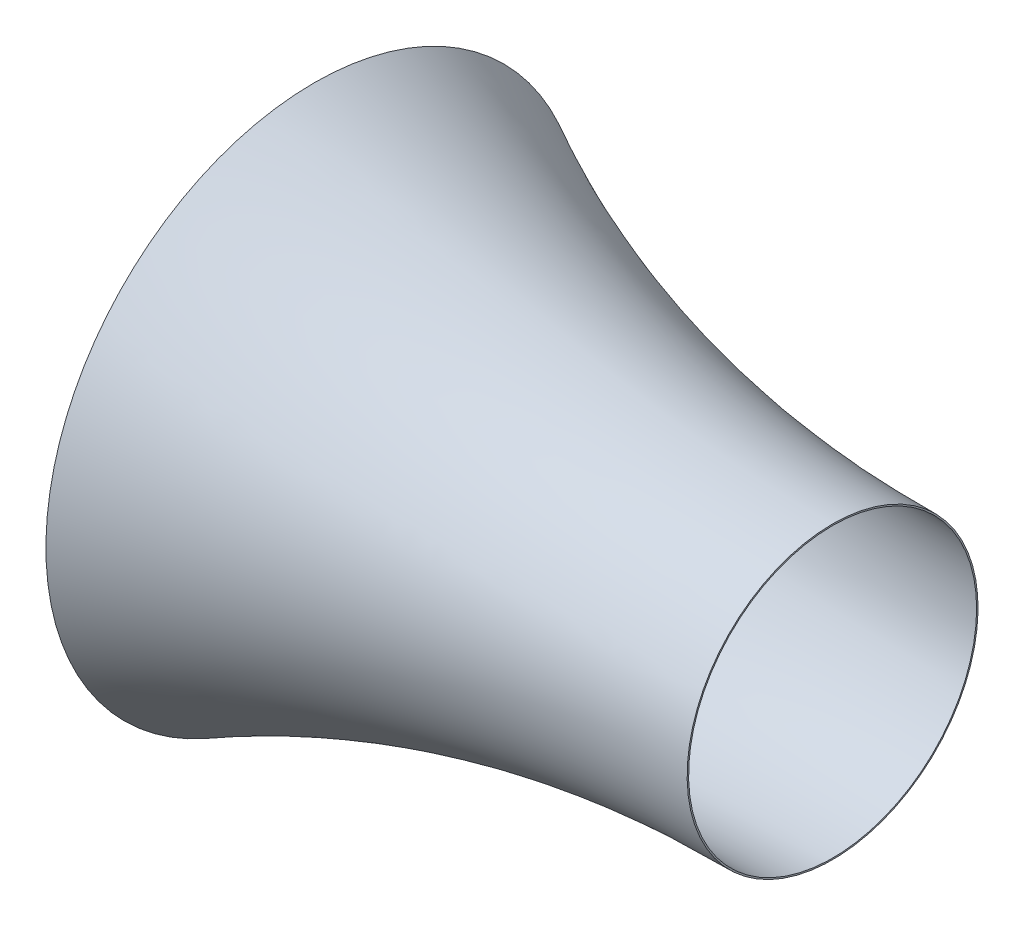
from build123d import *

# Parameters (mm, degrees)
THICKEN1_T1 = 5


with BuildPart() as body_1:
    # Surface-Revolve1: a surface, the sketch's curves turned about an axis
    with BuildLine(Plane.XY, mode=Mode.PRIVATE) as surface_revolve1_1_path:
        Line((58.164522356, 830), (33.164522356, 830))
        Line((33.164522356, 830), (25, 800))
        Line((25, 800), (0, 800))
        add(Edge.make_bspline(
            [(0, 800), (-40.64487716, 858.757553751), (0, 924.826053007)],
            knots=[0, 0, 0, 1, 1, 1], degree=2))
        add(Edge.make_bspline(
            [(0, 924.826053007), (832.327730928, 490.784309187), (1798, 500)],
            knots=[0, 0, 0, 1, 1, 1], degree=2))
    surface_revolve1_1 = Shell.revolve(surface_revolve1_1_path.wire(), 360, Axis((0, 0, 0), (1, 0, 0)))
    add(Solid.thicken(surface_revolve1_1, THICKEN1_T1))


solid = body_1.part
